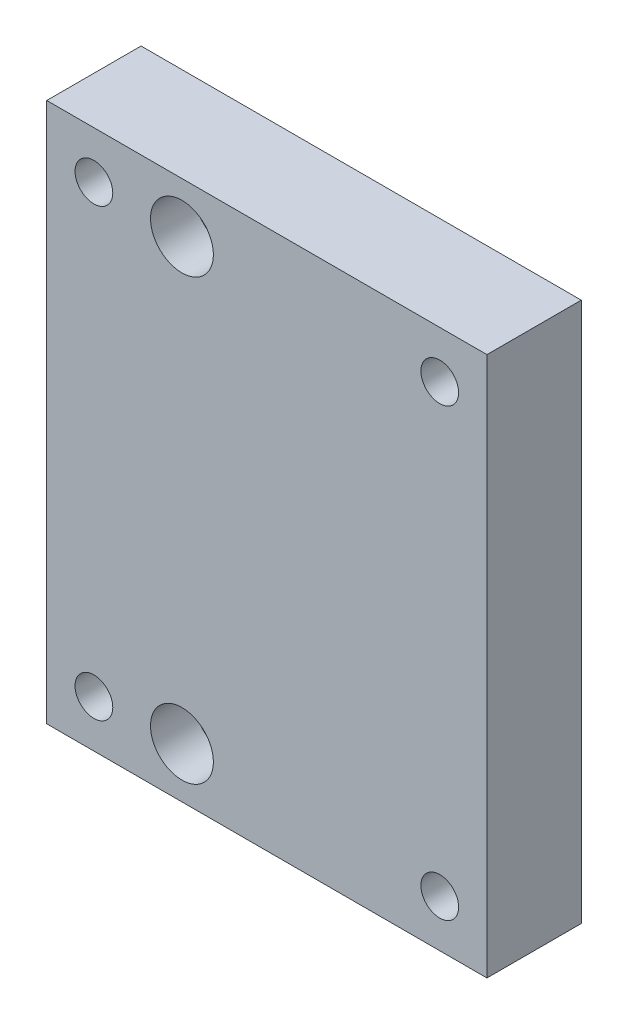
from build123d import *

# Parameters (mm, degrees)
SZKIC1_W                    = 70
SZKIC1_H                    = 85.85
DODANIE_WYCI_GNI_CIE1_DEPTH = 15
SZKIC2_R                    = 3
WYTNIJ_WYCI_GNI_CIE1_DEPTH  = 15
SZKIC3_R                    = 5
WYTNIJ_WYCI_GNI_CIE2_DEPTH  = 7
SZKIC4_R                    = 3
WYTNIJ_WYCI_GNI_CIE3_DEPTH  = 15
SZYK_LINIOWY1_COUNT         = 2
SZYK_LINIOWY1_PITCH         = 55
SZYK_LINIOWY1_COUNT_DIR2    = 2
SZYK_LINIOWY1_PITCH_DIR2    = 70.85


with BuildPart() as part:
    # Szkic1 → Dodanie-wyciągnięcie1 (new body)
    with BuildSketch(Plane.XY):
        Rectangle(SZKIC1_W, SZKIC1_H)
    extrude(amount=DODANIE_WYCI_GNI_CIE1_DEPTH)

    # Szkic2 → Wytnij-wyciągnięcie1 (cut)
    with BuildSketch(Plane.XY.offset(15)):
        with Locations((-13.5, 34.925)):
            Circle(SZKIC2_R)
        with Locations((-13.5, -34.925)):
            Circle(SZKIC2_R)
    extrude(amount=-WYTNIJ_WYCI_GNI_CIE1_DEPTH, mode=Mode.SUBTRACT)

    # Szkic3 → Wytnij-wyciągnięcie2 (cut)
    with BuildSketch(Plane.XY.offset(15)):
        with Locations((-13.5, 34.925)):
            Circle(SZKIC3_R)
        with Locations((-13.5, -34.925)):
            Circle(SZKIC3_R)
    extrude(amount=-WYTNIJ_WYCI_GNI_CIE2_DEPTH, mode=Mode.SUBTRACT)

    # Szkic4 → Wytnij-wyciągnięcie3 (cut)
    with BuildSketch(Plane.XY.offset(15)):
        with Locations((27.5, 35.425)):
            Circle(SZKIC4_R)
    wytnij_wyci_gni_cie3 = extrude(amount=-WYTNIJ_WYCI_GNI_CIE3_DEPTH, mode=Mode.SUBTRACT)

    # Szyk liniowy1: Wytnij-wyci_gni_cie3 2 × 2
    with Locations(*[(-i * SZYK_LINIOWY1_PITCH, -j * SZYK_LINIOWY1_PITCH_DIR2, 0) for i in range(SZYK_LINIOWY1_COUNT) for j in range(SZYK_LINIOWY1_COUNT_DIR2) if (i, j) != (0, 0)]):
        add(wytnij_wyci_gni_cie3, mode=Mode.SUBTRACT)


solid = part.part
